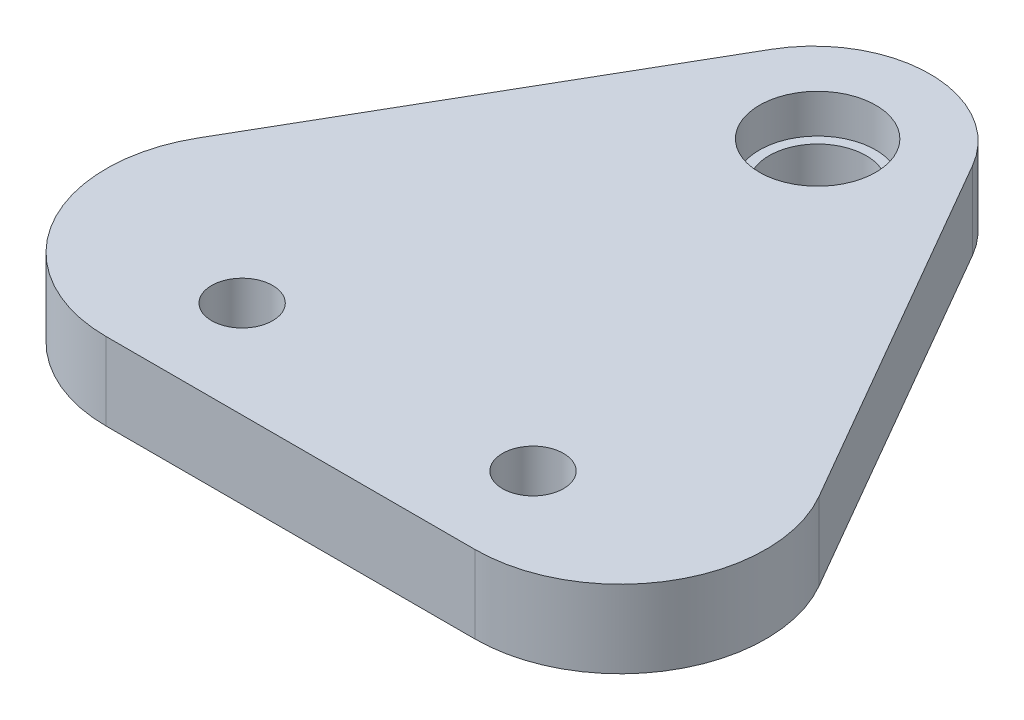
from build123d import *

# Parameters (mm, degrees)
BOSS_EXTRUDE1_DEPTH = 8
SKETCH2_R           = 6
SKETCH2_R_2         = 3
SKETCH2_R_3         = 3.15
CUT_EXTRUDE1_DEPTH  = 4
SKETCH3_R           = 5
CUT_EXTRUDE2_DEPTH  = 10
SKETCH4_R           = 3.15
CUT_EXTRUDE4_DEPTH  = 11


with BuildPart() as part:
    # Sketch1 → Boss-Extrude1 (new body)
    with BuildSketch(Plane(origin=(0, 0, 0), x_dir=(1, 0, 0), z_dir=(0, 1, 0))):
        with BuildLine():
            Line((12.990381057, 22.5), (34.607695155, 59.942286341))
            ThreePointArc((34.607695155, 59.942286341), (45, 65.942286341), (55.392304845, 59.942286341))
            Line((55.392304845, 59.942286341), (77.009618943, 22.5))
            ThreePointArc((77.009618943, 22.5), (77.009618943, 7.5), (64.019237886, 0))
            Line((64.019237886, 0), (25.980762114, 0))
            ThreePointArc((25.980762114, 0), (12.990381057, 7.5), (12.990381057, 22.5))
        make_face()
    extrude(amount=BOSS_EXTRUDE1_DEPTH)

    # Sketch2 → Cut-Extrude1 (cut)
    with BuildSketch(Plane(origin=(0, 8, 0), x_dir=(1, 0, 0), z_dir=(0, 1, 0))):
        with Locations((45, 54.358166274)):
            Circle(SKETCH2_R)
        with Locations((30, 10)):
            Circle(SKETCH2_R_2)
        with Locations((60, 10)):
            Circle(SKETCH2_R_3)
    extrude(amount=-CUT_EXTRUDE1_DEPTH, mode=Mode.SUBTRACT)

    # Sketch3 → Cut-Extrude2 (cut)
    with BuildSketch(Plane(origin=(0, 4, 0), x_dir=(1, 0, 0), z_dir=(0, 1, 0))):
        with Locations((45, 54.358166274)):
            Circle(SKETCH3_R)
    extrude(amount=-CUT_EXTRUDE2_DEPTH, mode=Mode.SUBTRACT)

    # Sketch4 → Cut-Extrude4 (cut)
    with BuildSketch(Plane(origin=(0, 0, 0), x_dir=(1, 0, 0), z_dir=(0, 1, 0))):
        with Locations((30, 10)):
            Circle(SKETCH4_R)
        with Locations((60, 10)):
            Circle(SKETCH4_R)
    extrude(amount=CUT_EXTRUDE4_DEPTH, mode=Mode.SUBTRACT)


solid = part.part
